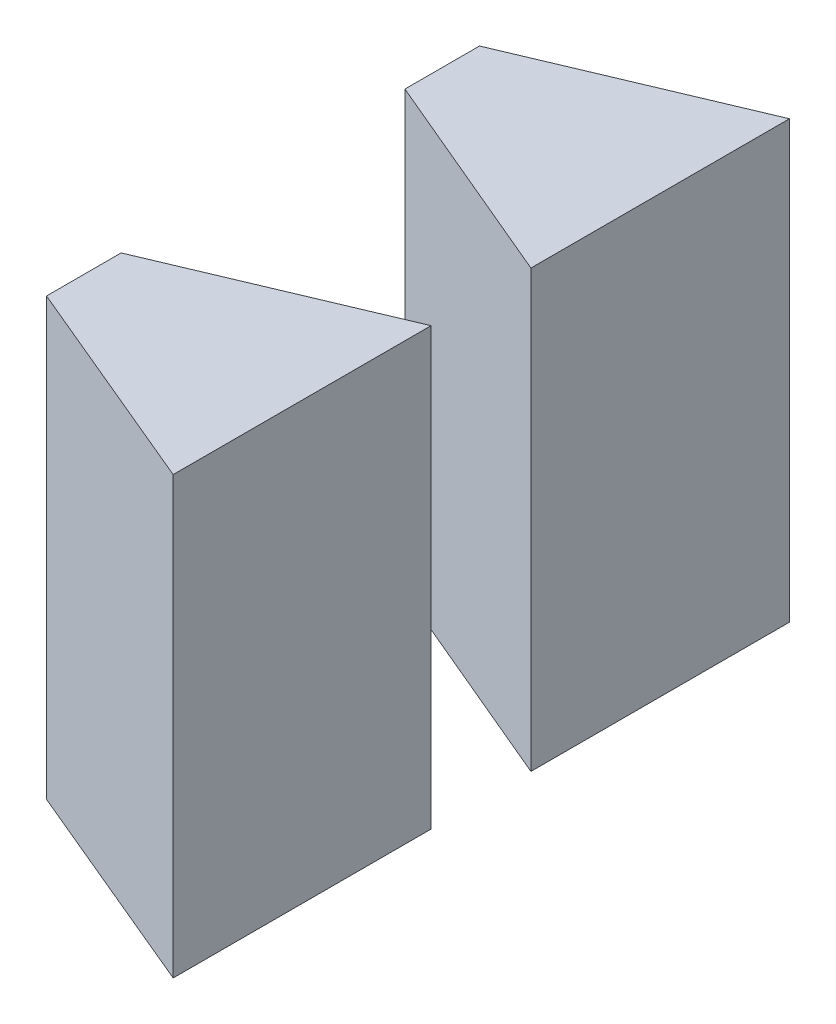
from build123d import *

# Parameters (mm, degrees)
SKETCH1_W               = 7.5
SKETCH1_H               = 27.66
BOSS_EXTRUDE1_DEPTH     = 25
SKETCH2_W               = 7.5
SKETCH2_H               = 27.66
CUT_EXTRUDE1_DEPTH      = 10
CUT_EXTRUDE2_DEPTH      = 1
CUT_EXTRUDE2_DEPTH_BACK = 16
CUT_EXTRUDE3_DEPTH      = 1
CUT_EXTRUDE3_DEPTH_BACK = 16


with BuildPart() as part:
    # Sketch1 → Boss-Extrude1 (new body)
    with BuildSketch(Plane(origin=(0, 0, 0), x_dir=(1, 0, 0), z_dir=(0, 1, 0))):
        with Locations((3.75, 13.83)):
            Rectangle(SKETCH1_W, SKETCH1_H)
    extrude(amount=BOSS_EXTRUDE1_DEPTH)

    # Sketch2 → Cut-Extrude1 (cut)
    with BuildSketch(Plane.XZ):
        with Locations((3.75, -13.83)):
            Rectangle(SKETCH2_W, SKETCH2_H)
    extrude(amount=-CUT_EXTRUDE1_DEPTH, mode=Mode.SUBTRACT)

    # Sketch3 → Cut-Extrude2 (cut, two sides)
    with BuildSketch(Plane.XZ.offset(-10)) as cut_extrude2_sk:
        Polygon((0, -5.948150323), (0, -6.381849677), (7.5, -3.239049355), (7.5, -2.805350002), align=None)
        Polygon((7.5, -12.112920844), (0, -8.947920844), (0, -9.382079156), (7.5, -12.547079156), align=None)
        Polygon((0, -17.626683376), (0, -18.712079156), (7.5, -15.547079156), (7.5, -14.461683376), align=None)
        Polygon((7.5, -24.442920844), (0, -21.277920844), (0, -21.712079156), (7.5, -24.877079156), align=None)
    extrude(amount=CUT_EXTRUDE2_DEPTH, mode=Mode.SUBTRACT)
    extrude(cut_extrude2_sk.sketch, amount=-CUT_EXTRUDE2_DEPTH_BACK, mode=Mode.SUBTRACT)

    # Sketch4 → Cut-Extrude3 (cut, two sides)
    with BuildSketch(Plane.XZ.offset(-10)) as cut_extrude3_sk:
        Polygon((0, 0), (7.5, 0), (7.5, -2.805350002), (0, -5.948150323), align=None)
        Polygon((0, -9.382079156), (7.5, -12.547079156), (7.5, -14.78730211), (0, -17.626683376), align=None)
        Polygon((0, -21.712079156), (7.5, -24.877079156), (7.5, -27.66), (0, -27.66), align=None)
    extrude(amount=CUT_EXTRUDE3_DEPTH, mode=Mode.SUBTRACT)
    extrude(cut_extrude3_sk.sketch, amount=-CUT_EXTRUDE3_DEPTH_BACK, mode=Mode.SUBTRACT)


solid = part.part
